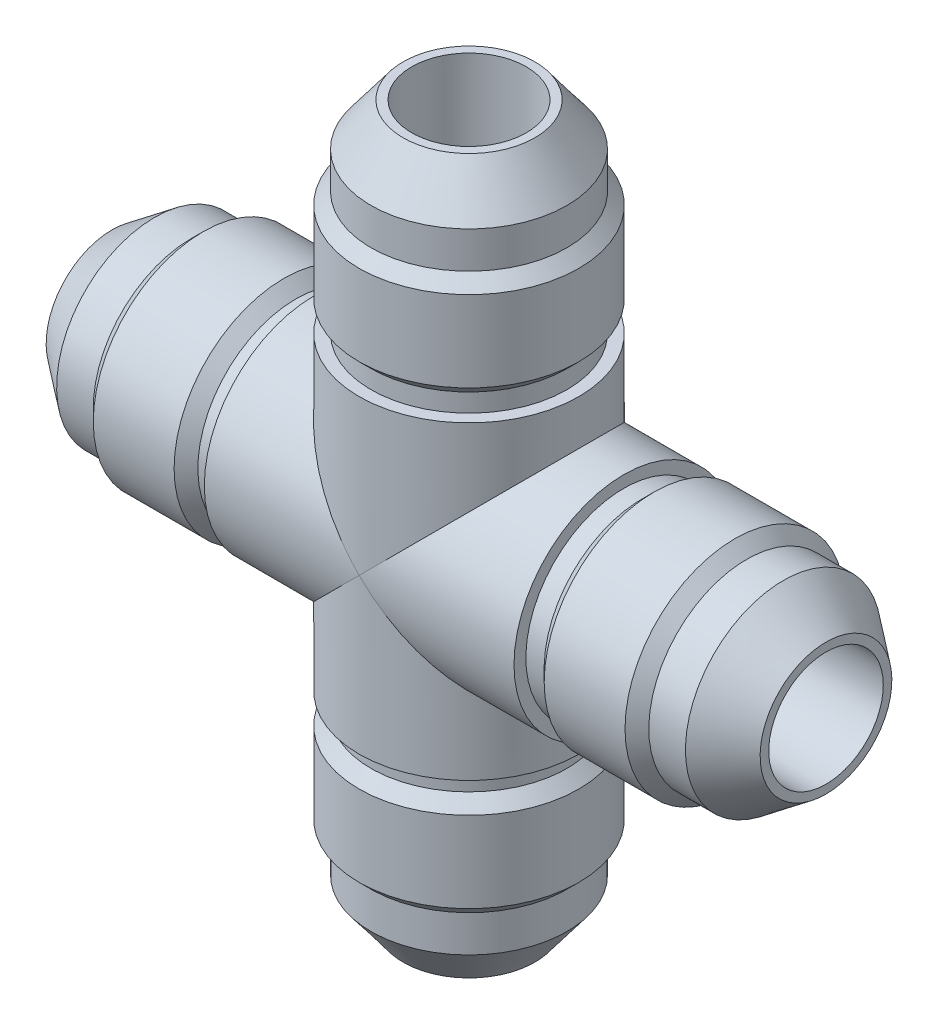
from build123d import *

# Parameters (mm, degrees)
SKETCH2_R           = 9.525
EXTRUDE1_DEPTH      = 17.526
SKETCH15_R          = 9.525
BOSS_EXTRUDE1_DEPTH = 13.4239
SKETCH16_R          = 4.9657
CUT_EXTRUDE1_DEPTH  = 31.9499
CIRPATTERN1_COUNT   = 4
CIRPATTERN1_ANGLE   = 270
SKETCH17_R          = 4.9657
CUT_EXTRUDE2_DEPTH  = 62.8998
CUT_EXTRUDE3_REACH  = 63.9
SKETCH18_R          = 4.9657


with BuildPart() as part:
    # Sketch2 → Extrude1 (new body)
    with BuildSketch(Plane(origin=(-30.9499, 0, 0), x_dir=(0, 0, -1), z_dir=(1, 0, 0))):
        Circle(SKETCH2_R)
    extrude(amount=EXTRUDE1_DEPTH)

    # Sketch5 → Cut-Revolve1 (revolve, cut)
    with BuildSketch(Plane.XY):
        Polygon((-27.256291687, 8.493888504), (-24.081291687, 8.493888504), (-23.050180191, 9.525), (-30.9499, 9.525), (-30.9499, 5.710555), align=None)
        Polygon((-13.4239, 8.493888504), (-15.0114, 8.493888504), (-16.042511496, 9.525), (-13.4239, 9.525), align=None)
    revolve(axis=Axis((0, 0, 0), (-1, 0, 0)), mode=Mode.SUBTRACT)

    # Sketch15 → Boss-Extrude1 (add)
    with BuildSketch(Plane(origin=(-13.4239, 0, 0), x_dir=(0, 0, -1), z_dir=(1, 0, 0))):
        Circle(SKETCH15_R)
    extrude(amount=BOSS_EXTRUDE1_DEPTH)

    # Sketch16 → Cut-Extrude1 (cut, through all)
    with BuildSketch(Plane(origin=(0, 0, 0), x_dir=(0, 0, -1), z_dir=(1, 0, 0))):
        Circle(SKETCH16_R)
    extrude(amount=-CUT_EXTRUDE1_DEPTH, mode=Mode.SUBTRACT)


with BuildPart() as cirpattern1_1:
    # CirPattern1: pattern copy
    add(part.part.rotate(Axis((0, 0, 0), (0, 0, -1)), 1 * CIRPATTERN1_ANGLE / (CIRPATTERN1_COUNT - 1)))

    # Sketch17 → Cut-Extrude2 (cut, through all)
    with BuildSketch(Plane.ZY.offset(30.9499)):
        Circle(SKETCH17_R)
    extrude(amount=-CUT_EXTRUDE2_DEPTH, mode=Mode.SUBTRACT)


with BuildPart() as cirpattern1_2:
    # CirPattern1: pattern copy
    add(part.part.rotate(Axis((0, 0, 0), (0, 0, -1)), 2 * CIRPATTERN1_ANGLE / (CIRPATTERN1_COUNT - 1)))


with BuildPart() as cirpattern1_3:
    # CirPattern1: pattern copy
    add(part.part.rotate(Axis((0, 0, 0), (0, 0, -1)), 3 * CIRPATTERN1_ANGLE / (CIRPATTERN1_COUNT - 1)))


with BuildPart() as cirpattern1_1_1:
    add(cirpattern1_1.part)

    # Combine1: union part, CirPattern1_2, CirPattern1_3
    add(part.part)
    add(cirpattern1_2.part)
    add(cirpattern1_3.part)

    # Sketch18 → Cut-Extrude3 (cut, up to next)
    with BuildSketch(Plane(origin=(0, 30.9499, 0), x_dir=(1, 0, 0), z_dir=(0, 1, 0)), mode=Mode.PRIVATE) as cut_extrude3_sk1:
        Circle(SKETCH18_R)
    cut_extrude3_tool1 = extrude(cut_extrude3_sk1.sketch, amount=-CUT_EXTRUDE3_REACH, mode=Mode.PRIVATE) & cirpattern1_1_1.part
    add(cut_extrude3_tool1.solids().sort_by_distance((0, 30.9499, 0))[0], mode=Mode.SUBTRACT)


solid = cirpattern1_1_1.part
